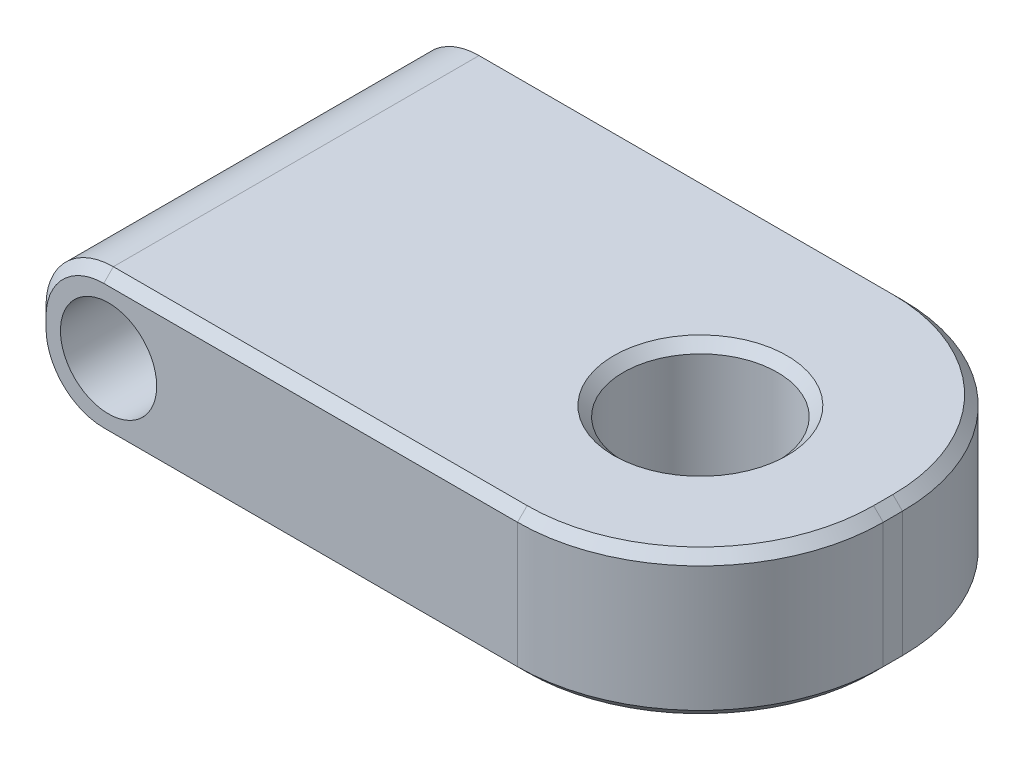
from build123d import *

# Parameters (mm, degrees)
BOSS_EXTRUDE1_DEPTH = 15
SKETCH2_R           = 5
CUT_EXTRUDE1_DEPTH  = 41
FILLET1_R           = 7
SKETCH3_R           = 8
CUT_EXTRUDE2_DEPTH  = 16
CHAMFER1_SIZE       = 1


with BuildPart() as part:
    # Sketch1 → Boss-Extrude1 (new body)
    with BuildSketch(Plane(origin=(0, 0, 0), x_dir=(1, 0, 0), z_dir=(0, 1, 0))):
        with BuildLine():
            Line((15.5, -20), (-34.5, -20))
            Line((-34.5, -20), (-34.5, 20))
            Line((-34.5, 20), (15.5, 20))
            ThreePointArc((15.5, 20), (28.935028843, 14.435028843), (34.5, 1))
            Line((34.5, 1), (34.5, -1))
            ThreePointArc((34.5, -1), (28.935028843, -14.435028843), (15.5, -20))
        make_face()
    extrude(amount=BOSS_EXTRUDE1_DEPTH)

    # Sketch2 → Cut-Extrude1 (cut, through all)
    with BuildSketch(Plane.XY.offset(20)):
        with Locations((-27, 7.5)):
            Circle(SKETCH2_R)
    extrude(amount=-CUT_EXTRUDE1_DEPTH, mode=Mode.SUBTRACT)

    # Fillet1
    fillet1_edges = [part.edges().sort_by_distance(p)[0] for p in [
        (-34.5, 15, 0),
        (-34.5, 0, 0),
    ]]
    fillet(fillet1_edges, radius=FILLET1_R)

    # Sketch3 → Cut-Extrude2 (cut, through all)
    with BuildSketch(Plane(origin=(0, 15, 0), x_dir=(1, 0, 0), z_dir=(0, 1, 0))):
        with Locations((15.5, -1)):
            Circle(SKETCH3_R)
    extrude(amount=-CUT_EXTRUDE2_DEPTH, mode=Mode.SUBTRACT)

    # Chamfer1
    chamfer1_edges = [part.edges().sort_by_distance(p)[0] for p in [
        (28.935028843, 15, 14.435028843),
        (34.5, 15, 0),
        (28.935028843, 15, -14.435028843),
        (-6, 15, -20),
        (-34.5, 7.5, 20),
        (-34.5, 7.5, -20),
        (-6, 0, 20),
        (-6, 15, 20),
        (-32.449747468, 12.949747468, 20),
        (-32.449747468, 2.050252532, 20),
        (-32.449747468, 12.949747468, -20),
        (-32.449747468, 2.050252532, -20),
        (7.5, 0, 1),
        (7.5, 15, 1),
        (-6, 0, -20),
        (28.935028843, 0, -14.435028843),
        (34.5, 0, 0),
        (28.935028843, 0, 14.435028843),
    ]]
    chamfer(chamfer1_edges, length=CHAMFER1_SIZE)


solid = part.part
